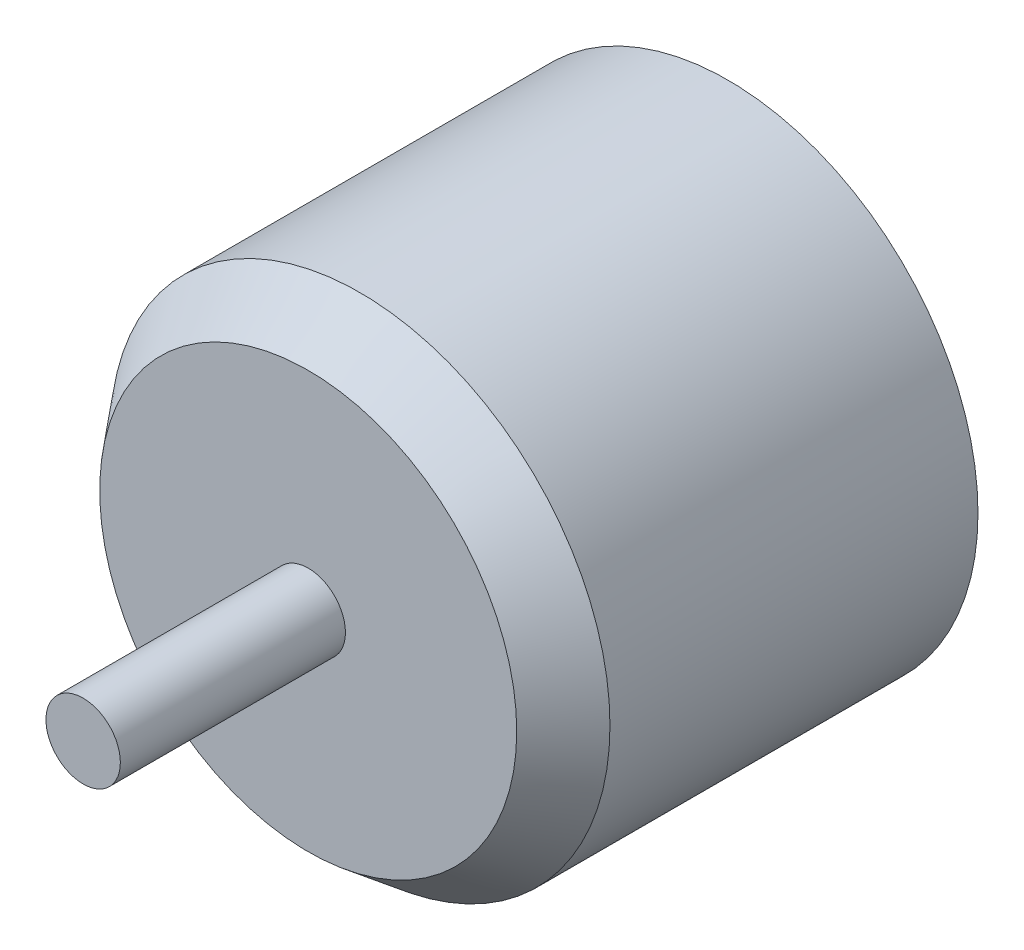
from build123d import *


with BuildPart() as part:
    # Sketch1 → Revolve1 (revolve)
    with BuildSketch(Plane(origin=(0, 0, 0), x_dir=(0, 0, -1), z_dir=(1, 0, 0))):
        Polygon((-24.2, 0), (55, 0), (55, 8.960625), (48.6, 8.960625), (48.6, 18.77175), (45.123477484, 26.881875), (5.558625, 26.881875), (0, 22.41675), (0, 4), (-24.2, 4), align=None)
    revolve(axis=Axis((0, 0, 67.9640625), (0, 0, -1)))


solid = part.part
